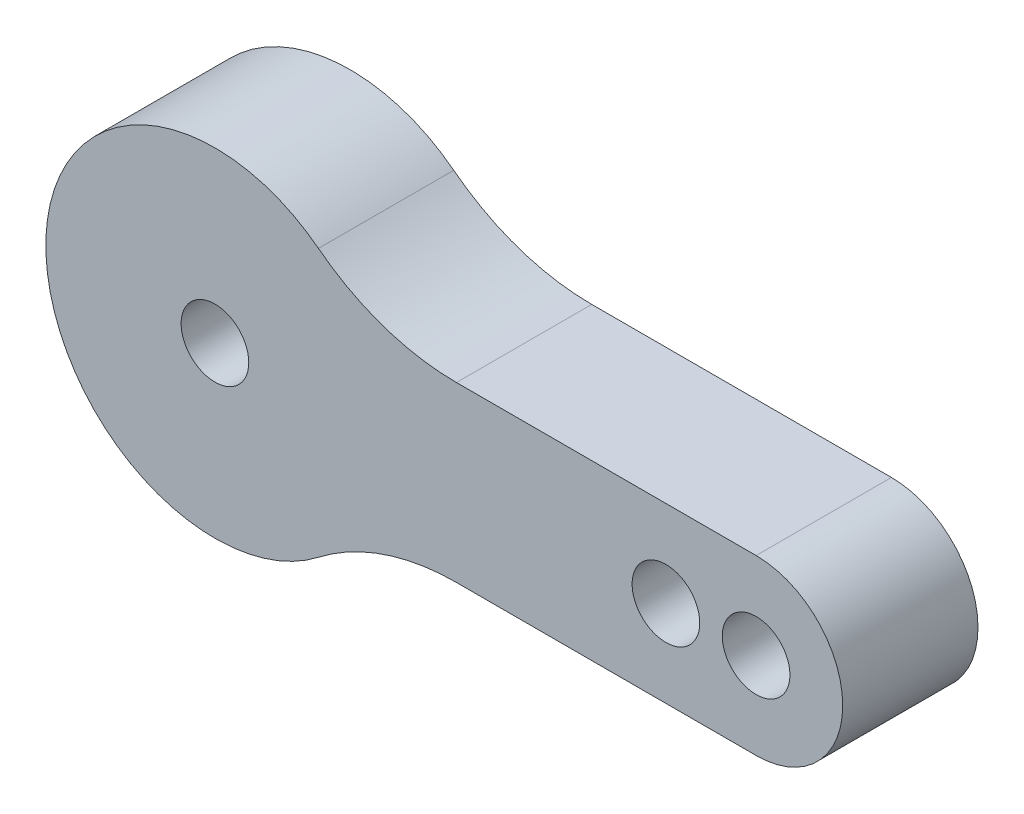
from build123d import *

# Parameters (mm, degrees)
SKETCH_1_R      = 1.5
EXTRUDE_2_DEPTH = 6


with BuildPart() as part:
    # 草图1 → 凸台-拉伸2 (new body)
    with BuildSketch(Plane.XY):
        with BuildLine():
            Line((24, 3.84), (10.710014006, 3.84))
            ThreePointArc((10.710014006, 3.84), (7.476263419, 4.377291236), (4.590006002, 5.931428571))
            ThreePointArc((4.590006002, 5.931428571), (-7.5, 0), (4.590006002, -5.931428571))
            ThreePointArc((4.590006002, -5.931428571), (7.476263419, -4.377291236), (10.710014006, -3.84))
            Line((10.710014006, -3.84), (24, -3.84))
            ThreePointArc((24, -3.84), (27.84, 0), (24, 3.84))
        make_face()
        Circle(SKETCH_1_R, mode=Mode.SUBTRACT)
        with Locations((20, 0)):
            Circle(SKETCH_1_R, mode=Mode.SUBTRACT)
        with Locations((24, 0)):
            Circle(SKETCH_1_R, mode=Mode.SUBTRACT)
    extrude(amount=EXTRUDE_2_DEPTH)


solid = part.part
